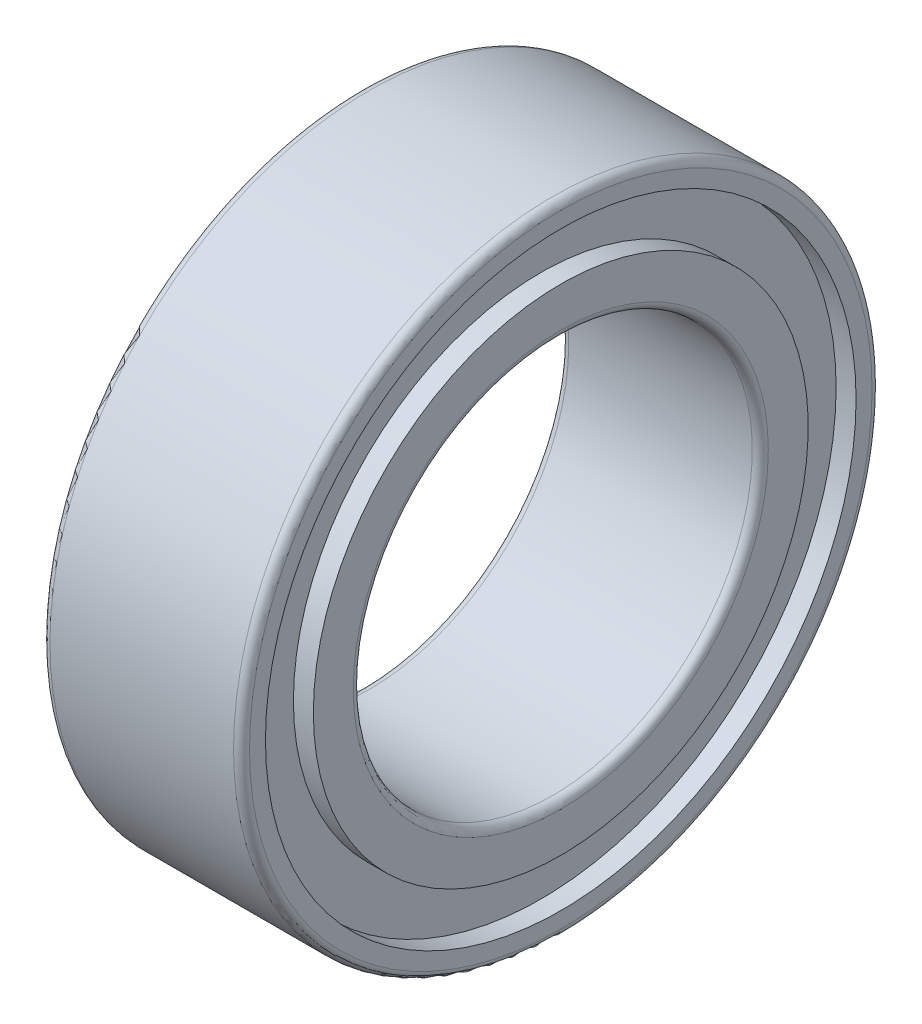
from build123d import *

# Parameters (mm, degrees)
FILLET1_R = 0.1


with BuildPart() as part:
    # Sketch1 → Revolve1 (revolve)
    with BuildSketch(Plane.XY):
        Polygon((0, 4), (0, 3.7), (0.25, 3.7), (0.25, 3.1), (0, 3.1), (0, 2.5), (2.5, 2.5), (2.5, 3.1), (2.25, 3.1), (2.25, 3.7), (2.5, 3.7), (2.5, 4), align=None)
    revolve(axis=Axis((0, 0, 0), (1, 0, 0)))

    # Fillet1
    fillet1_edges = [part.edges().sort_by_distance(p)[0] for p in [
        (2.5, -2.5, 0),
        (0, -2.5, 0),
        (0, -4, 0),
        (2.5, -4, 0),
    ]]
    fillet(fillet1_edges, radius=FILLET1_R)


solid = part.part
